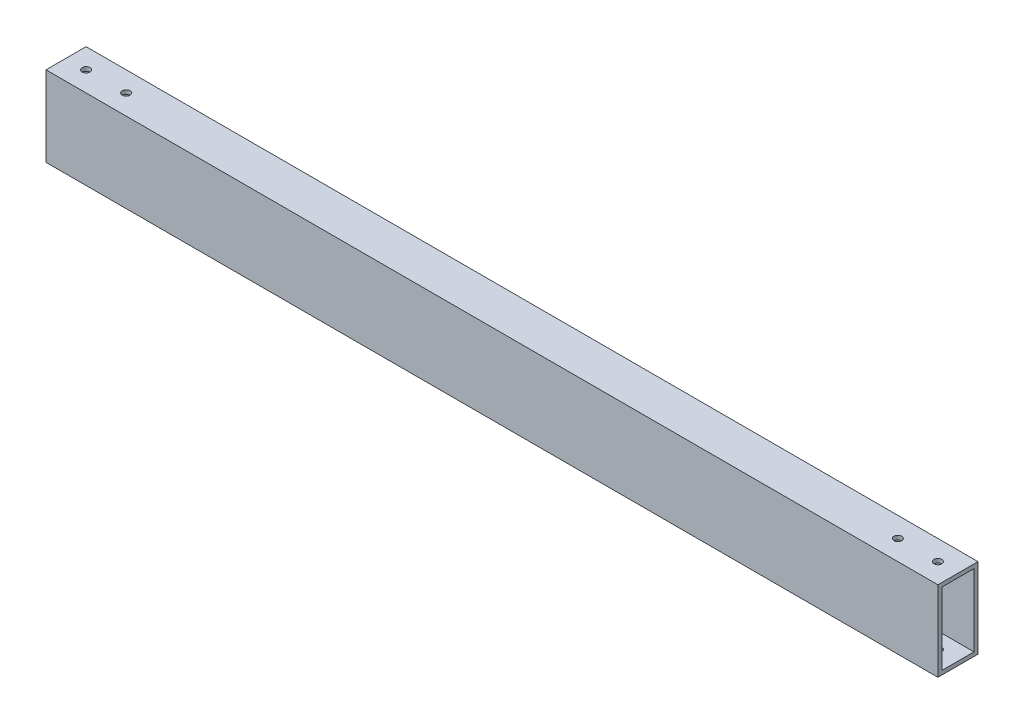
from build123d import *

# Parameters (mm, degrees)
SKETCH1_W           = 25.4
SKETCH1_H           = 50.8
SKETCH1_W_2         = 20.32
SKETCH1_H_2         = 45.72
EXTRUDE_THIN1_DEPTH = 282.575
SKETCH2_R           = 2.4765
CUT_EXTRUDE1_DEPTH  = 51.8


with BuildPart() as part:
    # Sketch1 → Extrude-Thin1 (new body, symmetric)
    with BuildSketch(Plane(origin=(0, 0, 0), x_dir=(0, 0, -1), z_dir=(1, 0, 0))):
        Rectangle(SKETCH1_W, SKETCH1_H)
        Rectangle(SKETCH1_W_2, SKETCH1_H_2, mode=Mode.SUBTRACT)
    extrude(amount=EXTRUDE_THIN1_DEPTH, both=True)

    # Sketch2 → Cut-Extrude1 (cut, through all)
    with BuildSketch(Plane(origin=(0, 25.4, 0), x_dir=(1, 0, 0), z_dir=(0, 1, 0))):
        with Locations((-269.875, 0)):
            Circle(SKETCH2_R)
        with Locations((-244.475, 0)):
            Circle(SKETCH2_R)
        with Locations((269.875, 0)):
            Circle(SKETCH2_R)
        with Locations((244.475, 0)):
            Circle(SKETCH2_R)
    extrude(amount=-CUT_EXTRUDE1_DEPTH, mode=Mode.SUBTRACT)


solid = part.part
